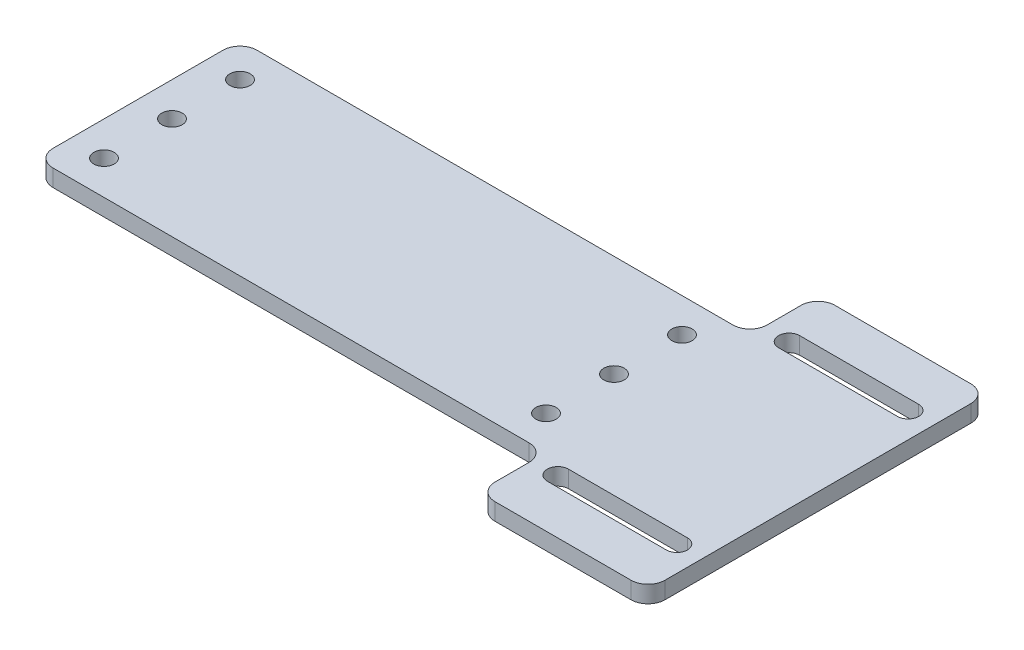
from build123d import *

# Parameters (mm, degrees)
SKETCH1_W           = 200
SKETCH1_H           = 60
BOSS_EXTRUDE1_DEPTH = 5
SKETCH2_R           = 3
CUT_EXTRUDE1_DEPTH  = 6
SKETCH3_W           = 50
SKETCH3_H           = 100
BOSS_EXTRUDE2_DEPTH = 5
CUT_EXTRUDE2_DEPTH  = 6
FILLET1_R           = 5


with BuildPart() as part:
    # Sketch1 → Boss-Extrude1 (new body)
    with BuildSketch(Plane(origin=(0, 0, 0), x_dir=(1, 0, 0), z_dir=(0, 1, 0))):
        Rectangle(SKETCH1_W, SKETCH1_H)
    extrude(amount=BOSS_EXTRUDE1_DEPTH)

    # Sketch2 → Cut-Extrude1 (cut, through all)
    with BuildSketch(Plane(origin=(0, 5, 0), x_dir=(1, 0, 0), z_dir=(0, 1, 0))):
        with Locations((-90, 20)):
            Circle(SKETCH2_R)
        with Locations((-90, -20)):
            Circle(SKETCH2_R)
        with Locations((40, -20)):
            Circle(SKETCH2_R)
        with Locations((40, 20)):
            Circle(SKETCH2_R)
        with Locations((-90, 0)):
            Circle(SKETCH2_R)
        with Locations((40, 0)):
            Circle(SKETCH2_R)
    extrude(amount=-CUT_EXTRUDE1_DEPTH, mode=Mode.SUBTRACT)

    # Sketch3 → Boss-Extrude2 (add)
    with BuildSketch(Plane(origin=(0, 0, 0), x_dir=(1, 0, 0), z_dir=(0, 1, 0))):
        with Locations((75, 0)):
            Rectangle(SKETCH3_W, SKETCH3_H)
    extrude(amount=BOSS_EXTRUDE2_DEPTH)

    # Sketch4 → Cut-Extrude2 (cut, through all)
    with BuildSketch(Plane(origin=(0, 5, 0), x_dir=(1, 0, 0), z_dir=(0, 1, 0))):
        with BuildLine():
            Line((57.5, -30.905), (92.5, -30.905))
            ThreePointArc((92.5, -30.905), (95.6, -34.005), (92.5, -37.105))
            Line((92.5, -37.105), (57.5, -37.105))
            ThreePointArc((57.5, -37.105), (54.4, -34.005), (57.5, -30.905))
        make_face()
    cut_extrude2 = extrude(amount=-CUT_EXTRUDE2_DEPTH, mode=Mode.SUBTRACT)

    # Mirror1: Cut-Extrude2 across plane
    add(cut_extrude2.mirror(Plane.XY), mode=Mode.SUBTRACT)

    # Fillet1
    fillet1_edges = [part.edges().sort_by_distance(p)[0] for p in [
        (100, 2.5, 50),
        (50, 2.5, -30),
        (50, 2.5, -50),
        (50, 2.5, 30),
        (100, 2.5, -50),
        (50, 2.5, 50),
        (-100, 2.5, 30),
        (-100, 2.5, -30),
    ]]
    fillet(fillet1_edges, radius=FILLET1_R)


solid = part.part
